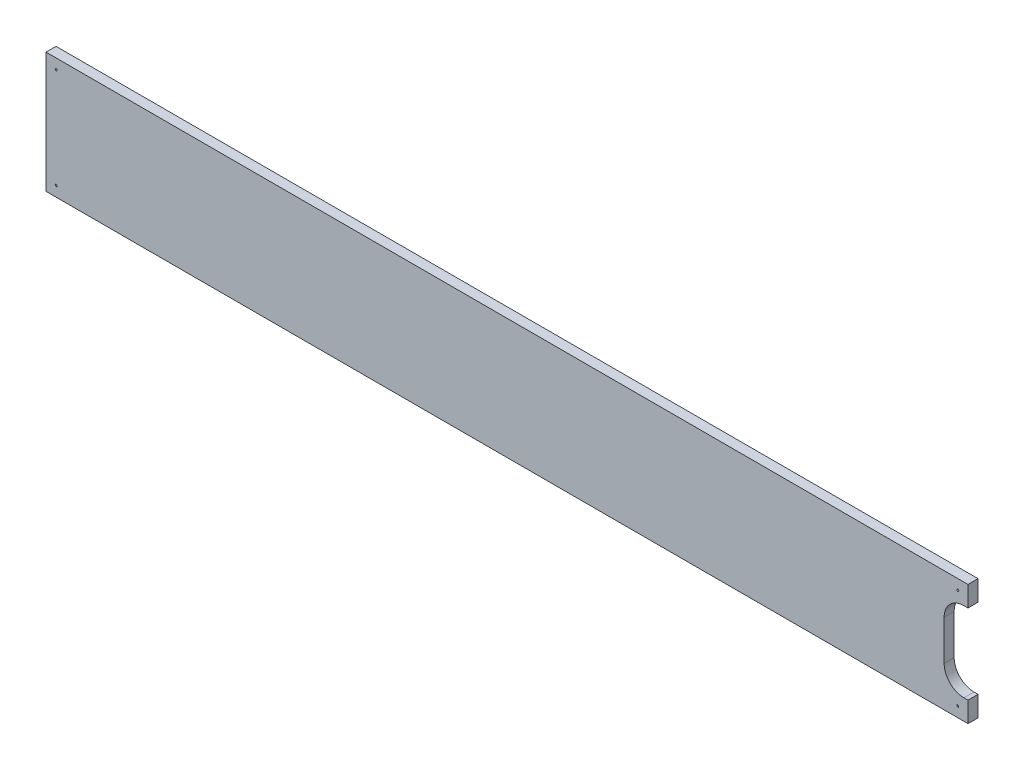
from build123d import *

# Parameters (mm, degrees)
ESQUISSE1_W                   = 460.2
ESQUISSE1_H                   = 60.2
BOSS_EXTRU_1_DEPTH            = 5
DIAM_TRE_DU_PER_AGE_1_0_1_1_D = 1
ENL_V_MAT_EXTRU_1_REACH       = 7


with BuildPart() as part:
    # Esquisse1 → Boss.-Extru.1 (new body)
    with BuildSketch(Plane.XY):
        with Locations((230, 30)):
            Rectangle(ESQUISSE1_W, ESQUISSE1_H)
    extrude(amount=BOSS_EXTRU_1_DEPTH)

    # Diamètre du perçage Ø1.0 (1)1 (through all)
    with Locations(Plane.XY.offset(5)):
        with Locations((5, 55), (5, 5), (455, 5), (455, 55)):
            Hole(DIAM_TRE_DU_PER_AGE_1_0_1_1_D / 2)

    # Esquisse4 → Enlèv. mat.-Extru.1 (cut, up to next)
    with BuildSketch(Plane.XY.offset(5), mode=Mode.PRIVATE) as enl_v_mat_extru_1_sk1:
        with BuildLine():
            Line((460.1, 10.1), (460.1, 49.9))
            Line((460.1, 49.9), (458.1, 49.9))
            ThreePointArc((458.1, 49.9), (451.099642866, 47.000357134), (448.2, 40))
            Line((448.2, 40), (448.2, 20))
            ThreePointArc((448.2, 20), (451.099642866, 12.999642866), (458.1, 10.1))
            Line((458.1, 10.1), (460.1, 10.1))
        make_face()
    enl_v_mat_extru_1_tool1 = extrude(enl_v_mat_extru_1_sk1.sketch, amount=-ENL_V_MAT_EXTRU_1_REACH, mode=Mode.PRIVATE) & part.part
    add(enl_v_mat_extru_1_tool1.solids().sort_by_distance((454.51443, 30, 5))[0], mode=Mode.SUBTRACT)


solid = part.part
